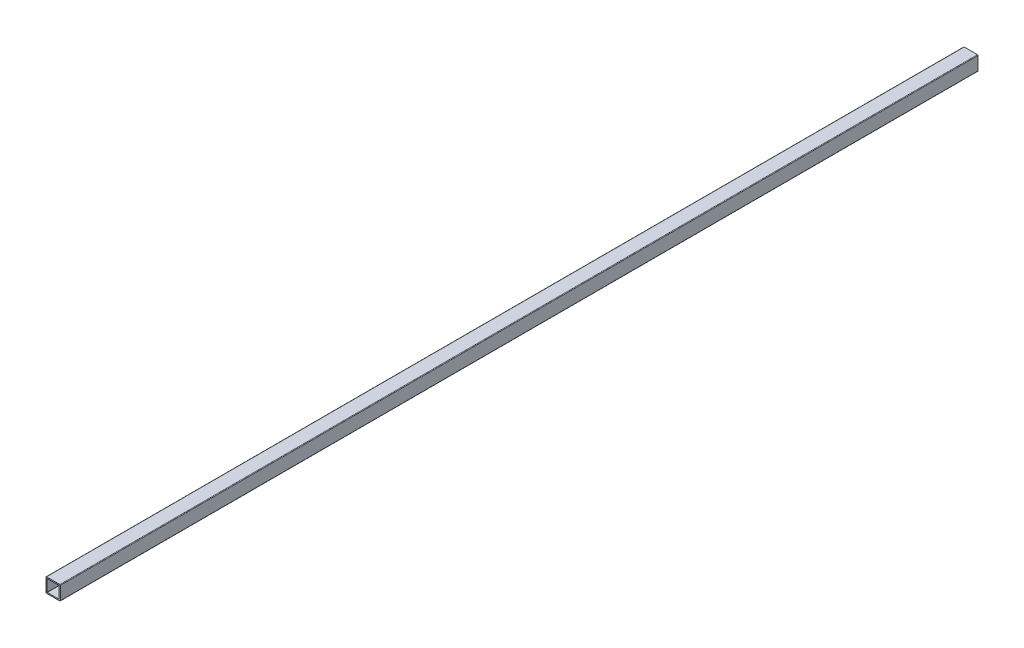
from build123d import *

# Parameters (mm, degrees)
SKETCH3_W                = 38.1
SKETCH3_H                = 38.1
SKETCH3_W_2              = 32.004
SKETCH3_H_2              = 32.004
BOSS_EXTRUDE1_DEPTH      = 1219.2
BOSS_EXTRUDE1_DEPTH_BACK = 1219.2
FILLET1_R                = 1.524
FILLET2_R                = 0.3048


with BuildPart() as part:
    # Sketch3 → Boss-Extrude1 (new body, two sides)
    with BuildSketch(Plane.XY) as boss_extrude1_sk:
        Rectangle(SKETCH3_W, SKETCH3_H)
        Rectangle(SKETCH3_W_2, SKETCH3_H_2, mode=Mode.SUBTRACT)
    extrude(amount=BOSS_EXTRUDE1_DEPTH)
    extrude(boss_extrude1_sk.sketch, amount=-BOSS_EXTRUDE1_DEPTH_BACK)

    # Fillet1
    fillet1_edges = [part.edges().sort_by_distance(p)[0] for p in [
        (-19.05, -19.05, 0),
        (-19.05, 19.05, 0),
        (19.05, 19.05, 0),
        (19.05, -19.05, 0),
    ]]
    fillet(fillet1_edges, radius=FILLET1_R)

    # Fillet2
    fillet2_edges = [part.edges().sort_by_distance(p)[0] for p in [
        (-16.002, -16.002, 0),
        (16.002, -16.002, 0),
        (16.002, 16.002, 0),
        (-16.002, 16.002, 0),
    ]]
    fillet(fillet2_edges, radius=FILLET2_R)


solid = part.part
